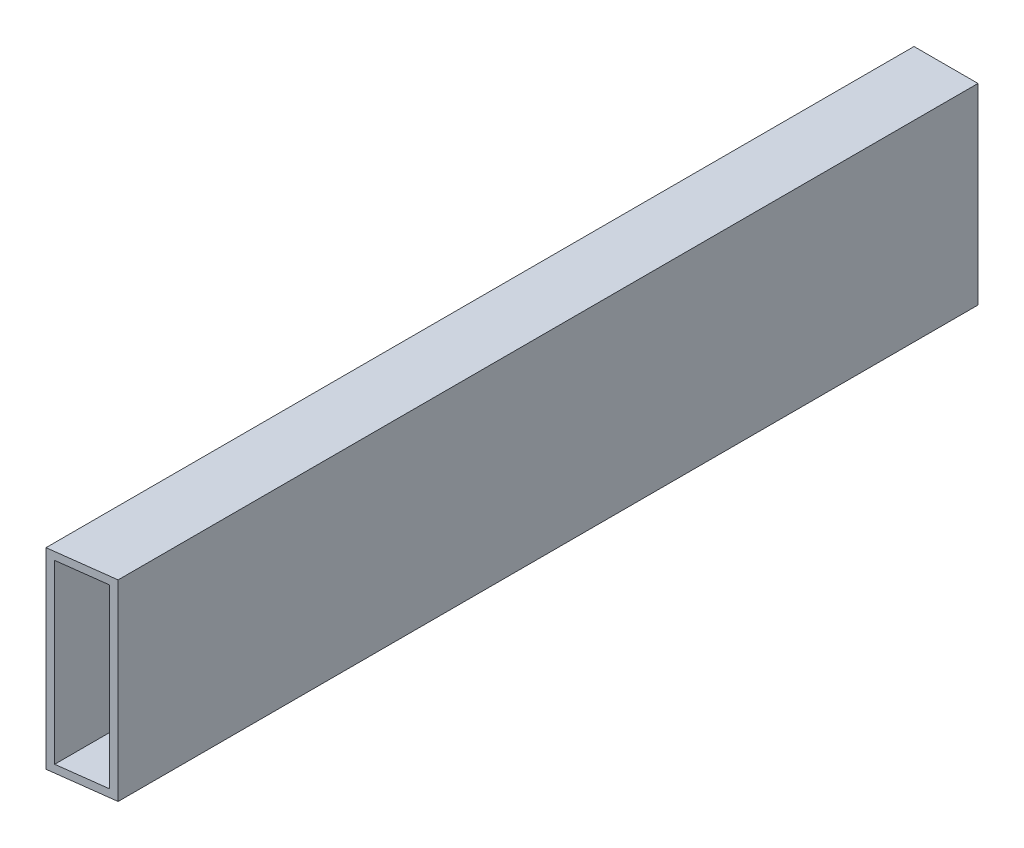
from build123d import *

# Parameters (mm, degrees)
SKETCH2_W               = 9.652
SKETCH2_H               = 3.048
SKETCH2_W_2             = 3.048
SKETCH2_H_2             = 35.052
BOSS_EXTRUDE1_DEPTH     = 343
SKETCH3_W               = 25.4
SKETCH3_H               = 76.2
SKETCH3_W_2             = 19.304
SKETCH3_H_2             = 70.104
BOSS_EXTRUDE2_DEPTH     = 50
CUT_EXTRUDE2_DEPTH      = 1
CUT_EXTRUDE2_DEPTH_BACK = 77.2


with BuildPart() as part:
    # Sketch2 → Boss-Extrude1 (new body)
    with BuildSketch(Plane.XY):
        Polygon((-12.7, 0), (-9.652, 0), (-9.652, 35.052), (-9.652, 38.1), (-12.7, 38.1), align=None)
        with Locations((-4.826, 36.576)):
            Rectangle(SKETCH2_W, SKETCH2_H)
        Polygon((0, 38.1), (0, 35.052), (9.652, 35.052), (9.652, 0), (12.7, 0), (12.7, 38.1), align=None)
        with Locations((11.176, -17.526)):
            Rectangle(SKETCH2_W_2, SKETCH2_H_2)
        Polygon((-9.652, -35.052), (-9.652, 0), (-12.7, 0), (-12.7, -38.1), (0, -38.1), (0, -35.052), align=None)
        Polygon((9.652, -35.052), (0, -35.052), (0, -38.1), (12.7, -38.1), (12.7, -35.052), align=None)
    extrude(amount=BOSS_EXTRUDE1_DEPTH)

    # Sketch3 → Boss-Extrude2 (add)
    with BuildSketch(Plane.XY.offset(343)):
        Rectangle(SKETCH3_W, SKETCH3_H)
        Rectangle(SKETCH3_W_2, SKETCH3_H_2, mode=Mode.SUBTRACT)
    extrude(amount=BOSS_EXTRUDE2_DEPTH)

    # Sketch5 → Cut-Extrude2 (cut, two sides)
    with BuildSketch(Plane(origin=(0, 38.1, 0), x_dir=(1, 0, 0), z_dir=(0, 1, 0))) as cut_extrude2_sk:
        Polygon((12.7, -391.250668344), (12.534006261, -391.403498707), (0, -343), (-12.7, -344.617644511), (-12.7, -393), (12.7, -393), align=None)
        Polygon((12.7, -341.382355489), (12.7, -391.250668344), (75.559800862, -333.375677395), align=None)
        Polygon((0, -343), (12.534006261, -391.403498707), (12.7, -391.250668344), (12.7, -341.382355489), align=None)
    extrude(amount=CUT_EXTRUDE2_DEPTH, mode=Mode.SUBTRACT)
    extrude(cut_extrude2_sk.sketch, amount=-CUT_EXTRUDE2_DEPTH_BACK, mode=Mode.SUBTRACT)


solid = part.part
